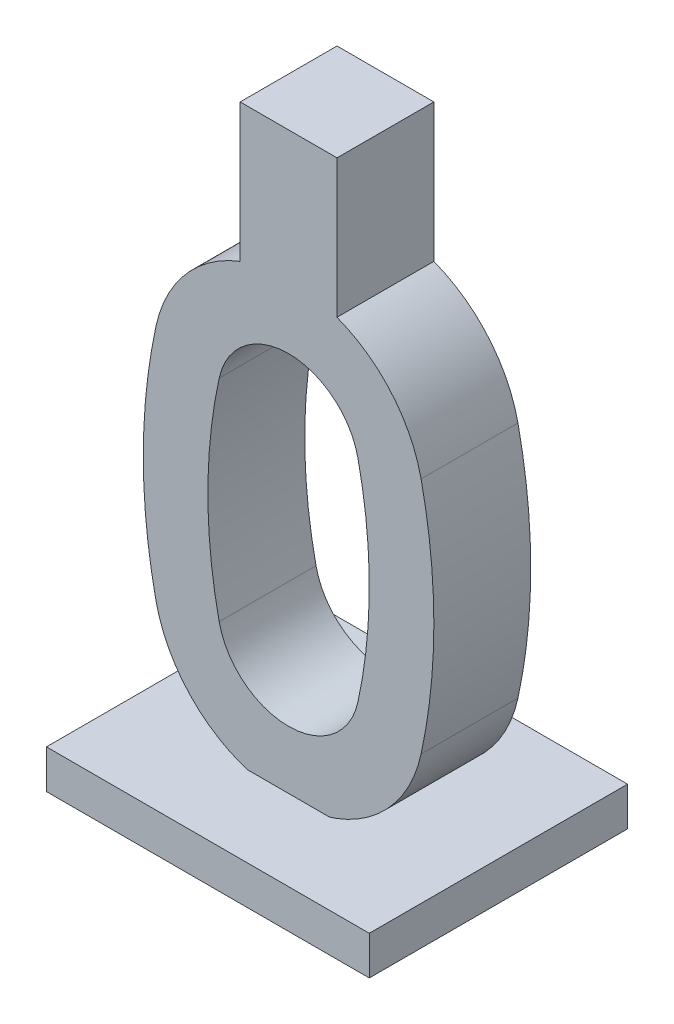
from build123d import *

# Parameters (mm, degrees)
AUFSATZ_LINEAR_AUSTRAGEN1_DEPTH      = 15
SKIZZE2_W                            = 50
SKIZZE2_H                            = 40
AUFSATZ_LINEAR_AUSTRAGEN2_DEPTH      = 1
AUFSATZ_LINEAR_AUSTRAGEN2_DEPTH_BACK = 5
SKIZZE3_W                            = 15
SKIZZE3_H                            = 21.384954754
AUFSATZ_LINEAR_AUSTRAGEN3_DEPTH      = 15


with BuildPart() as part:
    # Skizze1 → Aufsatz-Linear austragen1 (new body)
    with BuildSketch(Plane.XY):
        with BuildLine():
            ThreePointArc((20.52332913, 18.448928121), (0, 35), (-20.52332913, 18.448928121))
            ThreePointArc((-20.52332913, 18.448928121), (-22.5, 0), (-20.52332913, -18.448928121))
            ThreePointArc((-20.52332913, -18.448928121), (0, -35), (20.52332913, -18.448928121))
            ThreePointArc((20.52332913, -18.448928121), (22.5, 0), (20.52332913, 18.448928121))
        make_face()
        with BuildLine():
            ThreePointArc((10.750315259, 16.330390921), (0, 25), (-10.750315259, 16.330390921))
            ThreePointArc((-10.750315259, 16.330390921), (-12.5, 0), (-10.750315259, -16.330390921))
            ThreePointArc((-10.750315259, -16.330390921), (-6.905276963, -22.562543434), (0, -25))
            ThreePointArc((0, -25), (6.905276963, -22.562543434), (10.750315259, -16.330390921))
            ThreePointArc((10.750315259, -16.330390921), (12.5, 0), (10.750315259, 16.330390921))
        make_face(mode=Mode.SUBTRACT)
    extrude(amount=AUFSATZ_LINEAR_AUSTRAGEN1_DEPTH)

    # Skizze3 → Aufsatz-Linear austragen3 (add)
    with BuildSketch(Plane.XY.offset(15)):
        with Locations((0, 44.307522623)):
            Rectangle(SKIZZE3_W, SKIZZE3_H)
    extrude(amount=-AUFSATZ_LINEAR_AUSTRAGEN3_DEPTH)


with BuildPart() as body_2:
    # Skizze2 → Aufsatz-Linear austragen2 (new body, two sides)
    with BuildSketch(Plane(origin=(0, -35, 0), x_dir=(1, 0, 0), z_dir=(0, 1, 0))) as aufsatz_linear_austragen2_sk:
        with Locations((0, -7.5)):
            Rectangle(SKIZZE2_W, SKIZZE2_H)
    extrude(amount=AUFSATZ_LINEAR_AUSTRAGEN2_DEPTH)
    extrude(aufsatz_linear_austragen2_sk.sketch, amount=-AUFSATZ_LINEAR_AUSTRAGEN2_DEPTH_BACK)


solid = Compound([part.part, body_2.part])
